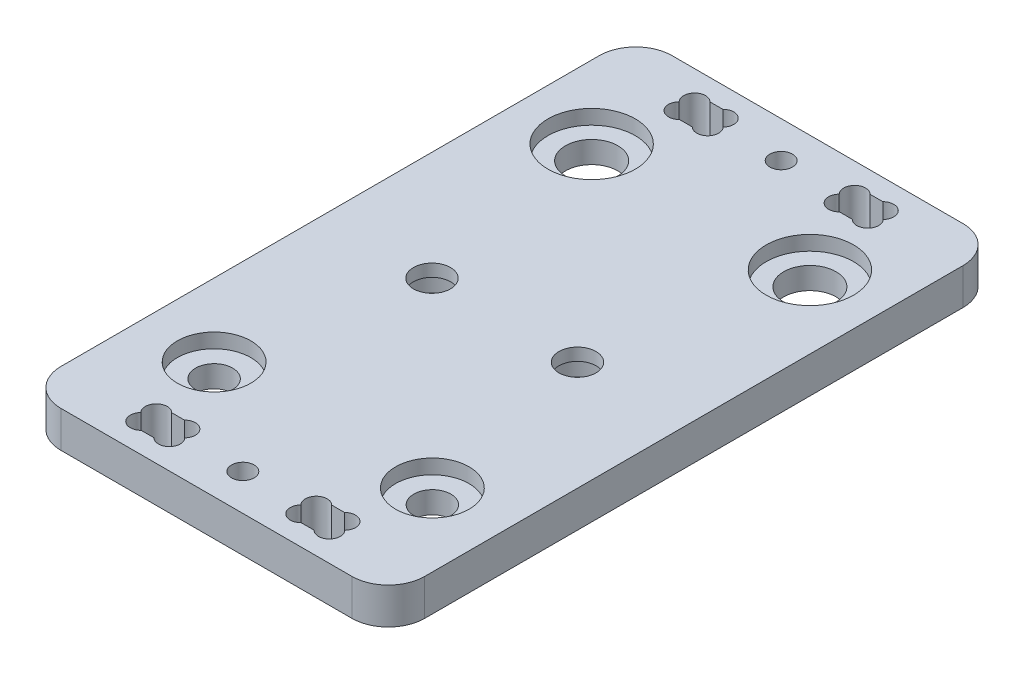
from build123d import *

# Parameters (mm, degrees)
SKETCH1_R               = 3.6
SKETCH1_R_2             = 2.55
BOSS_EXTRUDE1_DEPTH     = 5
SKETCH2_R               = 6
SKETCH2_R_2             = 5.05
CUT_EXTRUDE1_DEPTH      = 2
SALIENTE_EXTRUIR1_DEPTH = 5
CROQUIS5_R              = 2.55
CORTAR_EXTRUIR2_DEPTH   = 6
CROQUIS6_R              = 1.55
CROQUIS6_W              = 6
CROQUIS6_H              = 4.2
CORTAR_EXTRUIR3_DEPTH   = 6
CORTAR_EXTRUIR4_DEPTH   = 6
CROQUIS8_R              = 4.625
CORTAR_EXTRUIR5_DEPTH   = 3.3


with BuildPart() as part:
    # Sketch1 → Boss-Extrude1 (new body)
    with BuildSketch(Plane(origin=(0, 0, 0), x_dir=(1, 0, 0), z_dir=(0, 1, 0))):
        with BuildLine():
            Line((20.365, -35), (-20.365, -35))
            ThreePointArc((-20.365, -35), (-23.642439931, -33.642439931), (-25, -30.365))
            Line((-25, -30.365), (-25, 30.365))
            ThreePointArc((-25, 30.365), (-23.642439931, 33.642439931), (-20.365, 35))
            Line((-20.365, 35), (20.365, 35))
            ThreePointArc((20.365, 35), (23.642439931, 33.642439931), (25, 30.365))
            Line((25, 30.365), (25, -30.365))
            ThreePointArc((25, -30.365), (23.642439931, -33.642439931), (20.365, -35))
        make_face()
        with Locations((-15, 25.95)):
            Circle(SKETCH1_R, mode=Mode.SUBTRACT)
        with Locations((15, 25.95)):
            Circle(SKETCH1_R, mode=Mode.SUBTRACT)
        with Locations((15, -25.95)):
            Circle(SKETCH1_R_2, mode=Mode.SUBTRACT)
        with Locations((-15, -25.95)):
            Circle(SKETCH1_R_2, mode=Mode.SUBTRACT)
    extrude(amount=BOSS_EXTRUDE1_DEPTH)

    # Sketch2 → Cut-Extrude1 (cut)
    with BuildSketch(Plane(origin=(0, 5, 0), x_dir=(1, 0, 0), z_dir=(0, 1, 0))):
        with Locations((-15, 25.95)):
            Circle(SKETCH2_R)
        with Locations((15, 25.95)):
            Circle(SKETCH2_R)
        with Locations((15, -25.95)):
            Circle(SKETCH2_R_2)
        with Locations((-15, -25.95)):
            Circle(SKETCH2_R_2)
    extrude(amount=-CUT_EXTRUDE1_DEPTH, mode=Mode.SUBTRACT)

    # Croquis3 → Saliente-Extruir1 (add)
    with BuildSketch(Plane(origin=(0, 5, 0), x_dir=(1, 0, 0), z_dir=(0, 1, 0))):
        with BuildLine():
            Line((-25, 30.365), (-25, 37))
            ThreePointArc((-25, 37), (-23.535533906, 40.535533906), (-20, 42))
            Line((-20, 42), (20, 42))
            ThreePointArc((20, 42), (23.535533906, 40.535533906), (25, 37))
            Line((25, 37), (25, 30.365))
            ThreePointArc((25, 30.365), (23.642439931, 33.642439931), (20.365, 35))
            Line((20.365, 35), (-20.365, 35))
            ThreePointArc((-20.365, 35), (-23.642439931, 33.642439931), (-25, 30.365))
        make_face()
        with BuildLine():
            Line((-20.365, -35), (20.365, -35))
            ThreePointArc((20.365, -35), (23.642439931, -33.642439931), (25, -30.365))
            Line((25, -30.365), (25, -37))
            ThreePointArc((25, -37), (23.535533906, -40.535533906), (20, -42))
            Line((20, -42), (-20, -42))
            ThreePointArc((-20, -42), (-23.535533906, -40.535533906), (-25, -37))
            Line((-25, -37), (-25, -30.365))
            ThreePointArc((-25, -30.365), (-23.642439931, -33.642439931), (-20.365, -35))
        make_face()
    extrude(amount=-SALIENTE_EXTRUIR1_DEPTH)

    # Croquis5 → Cortar-Extruir2 (cut, through all)
    with BuildSketch(Plane.XZ):
        with Locations((10, 1)):
            Circle(CROQUIS5_R)
        with Locations((-10, 1)):
            Circle(CROQUIS5_R)
    extrude(amount=-CORTAR_EXTRUIR2_DEPTH, mode=Mode.SUBTRACT)

    # Croquis6 → Cortar-Extruir3 (cut, through all)
    with BuildSketch(Plane(origin=(0, 5, 0), x_dir=(1, 0, 0), z_dir=(0, 1, 0))):
        with Locations((0, -37)):
            Circle(CROQUIS6_R)
        with Locations((-11, -37)):
            Rectangle(CROQUIS6_W, CROQUIS6_H)
        with Locations((11, -37)):
            Rectangle(CROQUIS6_W, CROQUIS6_H)
    cortar_extruir3 = extrude(amount=-CORTAR_EXTRUIR3_DEPTH, mode=Mode.SUBTRACT)

    # Croquis7 → Cortar-Extruir4 (cut, through all)
    with BuildSketch(Plane.XZ):
        with BuildLine():
            Line((-11.878679656, 39.1), (-10.121320344, 39.1))
            ThreePointArc((-10.121320344, 39.1), (-8.010608171, 39.110503119), (-7.979099854, 37))
            ThreePointArc((-7.979099854, 37), (-8.010608171, 34.889496881), (-10.121320344, 34.9))
            Line((-10.121320344, 34.9), (-11.878679656, 34.9))
            ThreePointArc((-11.878679656, 34.9), (-13.989391829, 34.889496881), (-14.020900146, 37))
            ThreePointArc((-14.020900146, 37), (-13.989391829, 39.110503119), (-11.878679656, 39.1))
        make_face()
        with BuildLine():
            Line((11.878679656, 34.9), (10.121320344, 34.9))
            ThreePointArc((10.121320344, 34.9), (8.010608171, 34.889496881), (7.979099854, 37))
            ThreePointArc((7.979099854, 37), (8.010608171, 39.110503119), (10.121320344, 39.1))
            Line((10.121320344, 39.1), (11.878679656, 39.1))
            ThreePointArc((11.878679656, 39.1), (13.989391829, 39.110503119), (14.020900146, 37))
            ThreePointArc((14.020900146, 37), (13.989391829, 34.889496881), (11.878679656, 34.9))
        make_face()
    cortar_extruir4 = extrude(amount=-CORTAR_EXTRUIR4_DEPTH, mode=Mode.SUBTRACT)

    # Croquis8 → Cortar-Extruir5 (cut)
    with BuildSketch(Plane.XZ):
        with Locations((-10, 1)):
            Circle(CROQUIS8_R)
        with Locations((10, 1)):
            Circle(CROQUIS8_R)
    extrude(amount=-CORTAR_EXTRUIR5_DEPTH, mode=Mode.SUBTRACT)

    # Simetría1: Cortar-Extruir3, Cortar-Extruir4 across plane
    add(cortar_extruir3.mirror(Plane.XY), mode=Mode.SUBTRACT)
    add(cortar_extruir4.mirror(Plane.XY), mode=Mode.SUBTRACT)


solid = part.part
